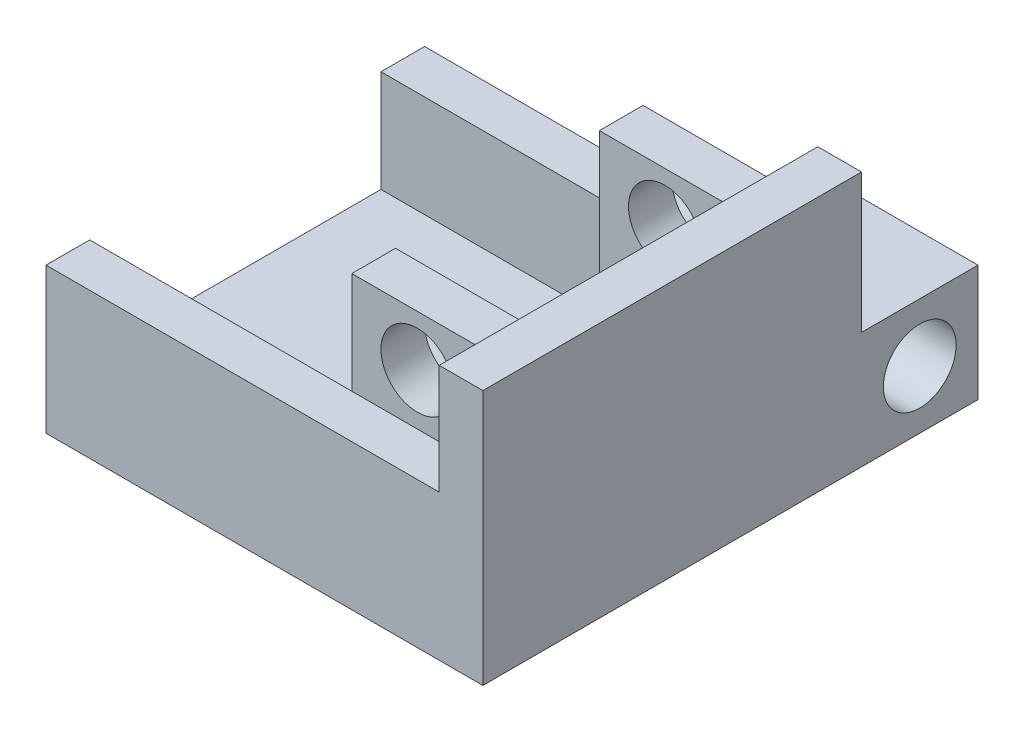
from build123d import *

# Parameters (mm, degrees)
SKETCH1_W               = 27
SKETCH1_H               = 20
SKETCH1_W_2             = 9
SKETCH1_H_2             = 3
BOSS_EXTRUDE1_DEPTH     = 3
BOSS_EXTRUDE2_START     = 3
SKETCH1_4_W             = 9
SKETCH1_4_H             = 3
BOSS_EXTRUDE2_DEPTH     = 4
SKETCH2_W               = 9
SKETCH2_H               = 6
BOSS_EXTRUDE3_DEPTH     = 3
BOSS_EXTRUDE4_START     = -4
SKETCH2_2_W             = 9
SKETCH2_2_H             = 6
BOSS_EXTRUDE4_DEPTH     = 2
SKETCH1_5_W             = 18
SKETCH1_5_H             = 3
BOSS_EXTRUDE5_DEPTH     = 10
SKETCH3_W               = 3
SKETCH3_H               = 26
BOSS_EXTRUDE6_DEPTH     = 7.54
SKETCH4_W               = 9
SKETCH4_H               = 3
BOSS_EXTRUDE7_DEPTH     = 7
SKETCH5_R               = 2.5
CUT_EXTRUDE1_DEPTH      = 4
CUT_EXTRUDE1_DEPTH_BACK = 24
SKETCH6_W               = 8
SKETCH6_H               = 8
SKETCH6_R               = 2.5
BOSS_EXTRUDE8_DEPTH     = 10


with BuildPart() as part:
    # Sketch1 → Boss-Extrude1 (new body)
    with BuildSketch(Plane(origin=(0, 0, 0), x_dir=(1, 0, 0), z_dir=(0, 1, 0))):
        Rectangle(SKETCH1_W, SKETCH1_H)
        with Locations((9, 11.5)):
            Rectangle(SKETCH1_W_2, SKETCH1_H_2)
        with Locations((9, -11.5)):
            Rectangle(SKETCH1_W_2, SKETCH1_H_2)
    extrude(amount=BOSS_EXTRUDE1_DEPTH)

    # Sketch1_4 → Boss-Extrude2 (add)
    with BuildSketch(Plane(origin=(0, 0, 0), x_dir=(1, 0, 0), z_dir=(0, 1, 0)).offset(BOSS_EXTRUDE2_START)):
        with Locations((9, -11.5)):
            Rectangle(SKETCH1_4_W, SKETCH1_4_H)
        with Locations((9, 11.5)):
            Rectangle(SKETCH1_4_W, SKETCH1_4_H)
    extrude(amount=BOSS_EXTRUDE2_DEPTH)

    # Sketch2 → Boss-Extrude3 (add)
    with BuildSketch(Plane(origin=(0, 7, 0), x_dir=(1, 0, 0), z_dir=(0, 1, 0))):
        with Locations((9, -10)):
            Rectangle(SKETCH2_W, SKETCH2_H)
        with Locations((9, 10)):
            Rectangle(SKETCH2_W, SKETCH2_H)
    extrude(amount=BOSS_EXTRUDE3_DEPTH)

    # Sketch2_2 → Boss-Extrude4 (add)
    with BuildSketch(Plane(origin=(0, 7, 0), x_dir=(1, 0, 0), z_dir=(0, 1, 0)).offset(BOSS_EXTRUDE4_START)):
        with Locations((9, -10)):
            Rectangle(SKETCH2_2_W, SKETCH2_2_H)
        with Locations((9, 10)):
            Rectangle(SKETCH2_2_W, SKETCH2_2_H)
    extrude(amount=BOSS_EXTRUDE4_DEPTH)

    # Sketch1_5 → Boss-Extrude5 (add)
    with BuildSketch(Plane(origin=(0, 0, 0), x_dir=(1, 0, 0), z_dir=(0, 1, 0))):
        Polygon((16.5, -13), (13.5, -13), (13.5, -10), (13.5, 10), (13.5, 13), (16.5, 13), align=None)
        with Locations((-4.5, -11.5)):
            Rectangle(SKETCH1_5_W, SKETCH1_5_H)
        with Locations((-4.5, 11.5)):
            Rectangle(SKETCH1_5_W, SKETCH1_5_H)
    extrude(amount=BOSS_EXTRUDE5_DEPTH)

    # Sketch3 → Boss-Extrude6 (add)
    with BuildSketch(Plane(origin=(0, 10, 0), x_dir=(1, 0, 0), z_dir=(0, 1, 0))):
        with Locations((15, 0)):
            Rectangle(SKETCH3_W, SKETCH3_H)
    extrude(amount=BOSS_EXTRUDE6_DEPTH)

    # Sketch4 → Boss-Extrude7 (add)
    with BuildSketch(Plane(origin=(0, 10, 0), x_dir=(1, 0, 0), z_dir=(0, 1, 0))):
        with Locations((9, 8.5)):
            Rectangle(SKETCH4_W, SKETCH4_H)
        with Locations((9, -8.5)):
            Rectangle(SKETCH4_W, SKETCH4_H)
    extrude(amount=BOSS_EXTRUDE7_DEPTH)

    # Sketch5 → Cut-Extrude1 (cut, two sides)
    with BuildSketch(Plane.XY.offset(10)) as cut_extrude1_sk:
        with Locations((9, 13.5)):
            Circle(SKETCH5_R)
    extrude(amount=CUT_EXTRUDE1_DEPTH, mode=Mode.SUBTRACT)
    extrude(cut_extrude1_sk.sketch, amount=-CUT_EXTRUDE1_DEPTH_BACK, mode=Mode.SUBTRACT)

    # Sketch6 → Boss-Extrude8 (add)
    with BuildSketch(Plane(origin=(16.5, 0, 0), x_dir=(0, 0, -1), z_dir=(1, 0, 0))):
        with Locations((17, 4)):
            Rectangle(SKETCH6_W, SKETCH6_H)
        with Locations((17, 4)):
            Circle(SKETCH6_R, mode=Mode.SUBTRACT)
    extrude(amount=-BOSS_EXTRUDE8_DEPTH)


solid = part.part
